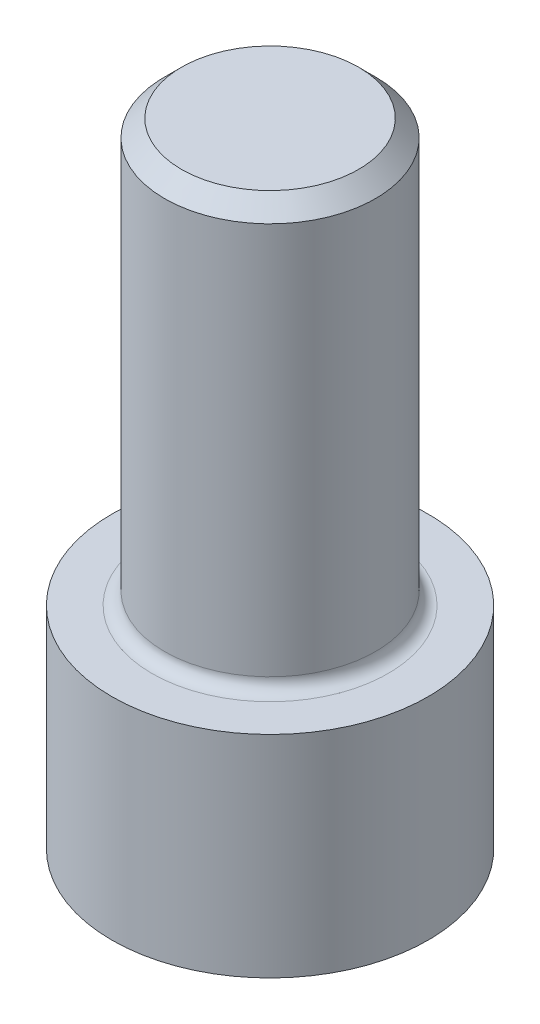
from build123d import *

# Parameters (mm, degrees)
SKETCH2_R           = 4.7625
BOSS_EXTRUDE1_DEPTH = 6.35
CUT_EXTRUDE1_DEPTH  = 3.81
SKETCH4_R           = 3.175
BOSS_EXTRUDE5_DEPTH = 12.7
FILLET2_R           = 0.381
CHAMFER1_SIZE       = 0.508


with BuildPart() as part:
    # Sketch2 → Boss-Extrude1 (new body)
    with BuildSketch(Plane(origin=(0, 0, 0), x_dir=(1, 0, 0), z_dir=(0, 1, 0))):
        Circle(SKETCH2_R)
    extrude(amount=BOSS_EXTRUDE1_DEPTH)

    # Sketch3 → Cut-Extrude1 (cut)
    with BuildSketch(Plane.XZ):
        Polygon((2.54, 0), (1.27, 2.199704526), (-1.27, 2.199704526), (-2.54, 0), (-1.27, -2.199704526), (1.27, -2.199704526), align=None)
    extrude(amount=-CUT_EXTRUDE1_DEPTH, mode=Mode.SUBTRACT)

    # Sketch4 → Boss-Extrude5 (add)
    with BuildSketch(Plane(origin=(0, 6.35, 0), x_dir=(1, 0, 0), z_dir=(0, 1, 0))):
        Circle(SKETCH4_R)
    extrude(amount=BOSS_EXTRUDE5_DEPTH)

    # Fillet2
    fillet2_edges = [part.edges().sort_by_distance(p)[0] for p in [
        (-3.175, 6.35, 0),
    ]]
    fillet(fillet2_edges, radius=FILLET2_R)

    # Chamfer1
    chamfer1_edges = [part.edges().sort_by_distance(p)[0] for p in [
        (-3.175, 19.05, 0),
    ]]
    chamfer(chamfer1_edges, length=CHAMFER1_SIZE)


solid = part.part
